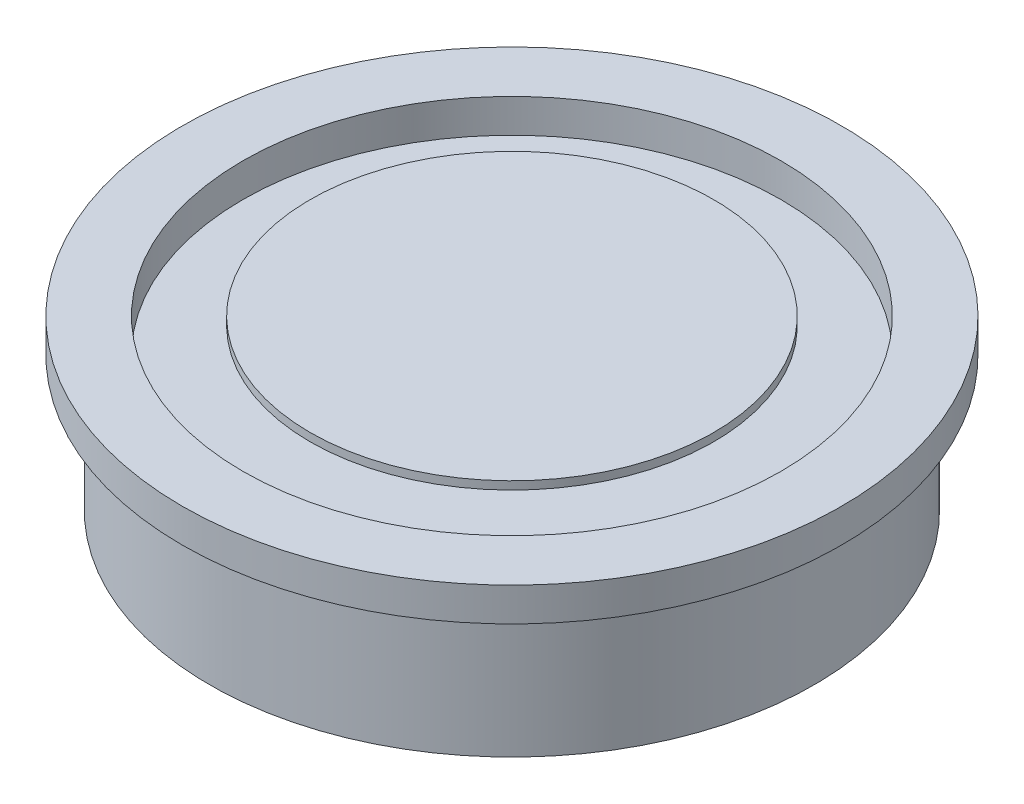
from build123d import *

# Parameters (mm, degrees)
SKETCH1_W                 = 15.5575
SKETCH1_H                 = 1.5875
M22_CLEARANCE_HOLE1_D     = 25.4
M22_CLEARANCE_HOLE1_DEPTH = 1.5875
SKETCH4_R                 = 9.525
BOSS_EXTRUDE1_DEPTH       = 0.381
SKETCH5_R                 = 14.2748
BOSS_EXTRUDE2_DEPTH       = 6.35
CUT_EXTRUDE1_DEPTH        = 6.35


with BuildPart() as part:
    # Sketch1 → Revolve1 (revolve)
    with BuildSketch(Plane(origin=(0, 0, 0), x_dir=(-1, 0, 0), z_dir=(0, 0, -1))):
        with Locations((-7.77875, 7.14375)):
            Rectangle(SKETCH1_W, SKETCH1_H)
    revolve(axis=Axis((0, 6.35, 0), (0, 1, 0)))

    # M22 Clearance Hole1
    with Locations(Plane(origin=(0, 7.9375, 0), x_dir=(1, 0, 0), z_dir=(0, 1, 0))):
        with Locations((0, 0)):
            Hole(M22_CLEARANCE_HOLE1_D / 2, depth=M22_CLEARANCE_HOLE1_DEPTH)

    # Sketch5 → Boss-Extrude2 (add)
    with BuildSketch(Plane.XZ.offset(-6.35)):
        Circle(SKETCH5_R)
    extrude(amount=BOSS_EXTRUDE2_DEPTH)

    # Sketch6 → Cut-Extrude1 (cut)
    with BuildSketch(Plane.XZ):
        Polygon((-3.671947712, 6.36), (-7.343895424, 0), (-3.671947712, -6.36), (3.671947712, -6.36), (7.343895424, 0), (3.671947712, 6.36), align=None)
    extrude(amount=-CUT_EXTRUDE1_DEPTH, mode=Mode.SUBTRACT)


with BuildPart() as body_2:
    # Sketch4 → Boss-Extrude1 (new body)
    with BuildSketch(Plane.XZ.offset(-7.5565)):
        Circle(SKETCH4_R)
    extrude(amount=-BOSS_EXTRUDE1_DEPTH)


solid = Compound([part.part, body_2.part])
